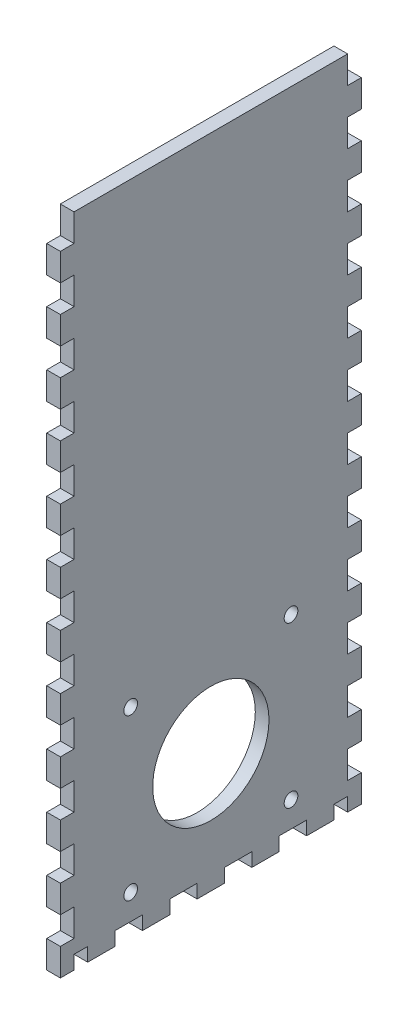
from build123d import *

# Parameters (mm, degrees)
SKETCH1_W              = 273.05
SKETCH1_H              = 139.7
BOSS_EXTRUDE1_DEPTH    = 6.35
SKETCH2_W              = 273.05
SKETCH2_H              = 139.7
SKETCH2_W_2            = 260.35
SKETCH2_H_2            = 127
BOSS_EXTRUDE2_DEPTH    = 298.45
SKETCH3_W              = 6.35
SKETCH3_H              = 16.933333333
SKETCH3_H_2            = 16.933333334
DOOR_SLOT_DEPTH        = 12.7
DOOR_GUIDE_HOLES_REACH = 361.617
SKETCH4_W              = 6.35
SKETCH4_H              = 15.875
LEVER_HOLES_W          = 9.652
LEVER_HOLES_H          = 6.35
LEVER_HOLES_W_2        = 6.35
CUT_EXTRUDE1_DEPTH     = 363.019620497
CUT_EXTRUDE2_REACH     = 417.137
SKETCH7_R              = 26.9875
CUT_EXTRUDE3_REACH     = 417.137
SKETCH8_R              = 3.175
SKETCH16_W             = 326.476778096
SKETCH16_H             = 315.233565403
CUT_EXTRUDE10_DEPTH    = 363.019620497
LEFT_RIGHT_W           = 6.35
LEFT_RIGHT_H           = 6.35
LEFT_RIGHT_W_2         = 12.7
LEFT_RIGHT_H_2         = 12.7
CUT_EXTRUDE11_DEPTH    = 416.136561869


with BuildPart() as part:
    # Sketch1 → Boss-Extrude1 (new body)
    with BuildSketch(Plane(origin=(0, 0, 0), x_dir=(1, 0, 0), z_dir=(0, 1, 0))):
        Rectangle(SKETCH1_W, SKETCH1_H)
    extrude(amount=BOSS_EXTRUDE1_DEPTH)

    # Sketch2 → Boss-Extrude2 (add)
    with BuildSketch(Plane(origin=(0, 6.35, 0), x_dir=(1, 0, 0), z_dir=(0, 1, 0))):
        Rectangle(SKETCH2_W, SKETCH2_H)
        Rectangle(SKETCH2_W_2, SKETCH2_H_2, mode=Mode.SUBTRACT)
    extrude(amount=BOSS_EXTRUDE2_DEPTH)

    # Sketch3 → Door Slot (cut)
    with BuildSketch(Plane.XY.offset(69.85)):
        with BuildLine():
            Line((-28.575, 283.21), (-28.575, 6.35))
            Line((-28.575, 6.35), (-21.971, 6.35))
            Line((-21.971, 6.35), (-21.971, 292.354))
            Line((-21.971, 292.354), (-41.529, 292.354))
            Line((-41.529, 292.354), (-41.529, 285.75))
            Line((-41.529, 285.75), (-31.115, 285.75))
            ThreePointArc((-31.115, 285.75), (-29.318948776, 285.006051224), (-28.575, 283.21))
        make_face()
        with Locations((-12.446, 80.433333334)):
            Rectangle(SKETCH3_W, SKETCH3_H)
        with Locations((-12.446, 50.8)):
            Rectangle(SKETCH3_W, SKETCH3_H_2)
        with Locations((-12.446, 21.166666667)):
            Rectangle(SKETCH3_W, SKETCH3_H)
    extrude(amount=-DOOR_SLOT_DEPTH, mode=Mode.SUBTRACT)

    # Sketch4 → Door Guide Holes (cut, up to next)
    with BuildSketch(Plane.XY.offset(-63.5), mode=Mode.PRIVATE) as door_guide_holes_sk1:
        with Locations((-44.704, 284.1625)):
            Rectangle(SKETCH4_W, SKETCH4_H)
    door_guide_holes_tool1 = extrude(door_guide_holes_sk1.sketch, amount=-DOOR_GUIDE_HOLES_REACH, mode=Mode.PRIVATE) & part.part
    # Sketch4 → Door Guide Holes (cut, up to next)
    with BuildSketch(Plane.XY.offset(-63.5), mode=Mode.PRIVATE) as door_guide_holes_sk2:
        with Locations((-44.704, 255.5875)):
            Rectangle(SKETCH4_W, SKETCH4_H)
    door_guide_holes_tool2 = extrude(door_guide_holes_sk2.sketch, amount=-DOOR_GUIDE_HOLES_REACH, mode=Mode.PRIVATE) & part.part
    # Sketch4 → Door Guide Holes (cut, up to next)
    with BuildSketch(Plane.XY.offset(-63.5), mode=Mode.PRIVATE) as door_guide_holes_sk3:
        with Locations((-44.704, 227.0125)):
            Rectangle(SKETCH4_W, SKETCH4_H)
    door_guide_holes_tool3 = extrude(door_guide_holes_sk3.sketch, amount=-DOOR_GUIDE_HOLES_REACH, mode=Mode.PRIVATE) & part.part
    # Sketch4 → Door Guide Holes (cut, up to next)
    with BuildSketch(Plane.XY.offset(-63.5), mode=Mode.PRIVATE) as door_guide_holes_sk4:
        with Locations((-44.704, 198.4375)):
            Rectangle(SKETCH4_W, SKETCH4_H)
    door_guide_holes_tool4 = extrude(door_guide_holes_sk4.sketch, amount=-DOOR_GUIDE_HOLES_REACH, mode=Mode.PRIVATE) & part.part
    # Sketch4 → Door Guide Holes (cut, up to next)
    with BuildSketch(Plane.XY.offset(-63.5), mode=Mode.PRIVATE) as door_guide_holes_sk5:
        with Locations((-44.704, 169.8625)):
            Rectangle(SKETCH4_W, SKETCH4_H)
    door_guide_holes_tool5 = extrude(door_guide_holes_sk5.sketch, amount=-DOOR_GUIDE_HOLES_REACH, mode=Mode.PRIVATE) & part.part
    # Sketch4 → Door Guide Holes (cut, up to next)
    with BuildSketch(Plane.XY.offset(-63.5), mode=Mode.PRIVATE) as door_guide_holes_sk6:
        with Locations((-44.704, 141.2875)):
            Rectangle(SKETCH4_W, SKETCH4_H)
    door_guide_holes_tool6 = extrude(door_guide_holes_sk6.sketch, amount=-DOOR_GUIDE_HOLES_REACH, mode=Mode.PRIVATE) & part.part
    # Sketch4 → Door Guide Holes (cut, up to next)
    with BuildSketch(Plane.XY.offset(-63.5), mode=Mode.PRIVATE) as door_guide_holes_sk7:
        with Locations((-44.704, 112.7125)):
            Rectangle(SKETCH4_W, SKETCH4_H)
    door_guide_holes_tool7 = extrude(door_guide_holes_sk7.sketch, amount=-DOOR_GUIDE_HOLES_REACH, mode=Mode.PRIVATE) & part.part
    # Sketch4 → Door Guide Holes (cut, up to next)
    with BuildSketch(Plane.XY.offset(-63.5), mode=Mode.PRIVATE) as door_guide_holes_sk8:
        with Locations((-44.704, 84.1375)):
            Rectangle(SKETCH4_W, SKETCH4_H)
    door_guide_holes_tool8 = extrude(door_guide_holes_sk8.sketch, amount=-DOOR_GUIDE_HOLES_REACH, mode=Mode.PRIVATE) & part.part
    # Sketch4 → Door Guide Holes (cut, up to next)
    with BuildSketch(Plane.XY.offset(-63.5), mode=Mode.PRIVATE) as door_guide_holes_sk9:
        with Locations((-44.704, 55.5625)):
            Rectangle(SKETCH4_W, SKETCH4_H)
    door_guide_holes_tool9 = extrude(door_guide_holes_sk9.sketch, amount=-DOOR_GUIDE_HOLES_REACH, mode=Mode.PRIVATE) & part.part
    # Sketch4 → Door Guide Holes (cut, up to next)
    with BuildSketch(Plane.XY.offset(-63.5), mode=Mode.PRIVATE) as door_guide_holes_sk10:
        with Locations((-44.704, 26.9875)):
            Rectangle(SKETCH4_W, SKETCH4_H)
    door_guide_holes_tool10 = extrude(door_guide_holes_sk10.sketch, amount=-DOOR_GUIDE_HOLES_REACH, mode=Mode.PRIVATE) & part.part
    door_guide_holes_1 = door_guide_holes_tool1.solids().sort_by_distance((-44.704, 284.1625, -63.5))[0]
    add(door_guide_holes_1, mode=Mode.SUBTRACT)
    door_guide_holes_2 = door_guide_holes_tool2.solids().sort_by_distance((-44.704, 255.5875, -63.5))[0]
    add(door_guide_holes_2, mode=Mode.SUBTRACT)
    door_guide_holes_3 = door_guide_holes_tool3.solids().sort_by_distance((-44.704, 227.0125, -63.5))[0]
    add(door_guide_holes_3, mode=Mode.SUBTRACT)
    door_guide_holes_4 = door_guide_holes_tool4.solids().sort_by_distance((-44.704, 198.4375, -63.5))[0]
    add(door_guide_holes_4, mode=Mode.SUBTRACT)
    door_guide_holes_5 = door_guide_holes_tool5.solids().sort_by_distance((-44.704, 169.8625, -63.5))[0]
    add(door_guide_holes_5, mode=Mode.SUBTRACT)
    door_guide_holes_6 = door_guide_holes_tool6.solids().sort_by_distance((-44.704, 141.2875, -63.5))[0]
    add(door_guide_holes_6, mode=Mode.SUBTRACT)
    door_guide_holes_7 = door_guide_holes_tool7.solids().sort_by_distance((-44.704, 112.7125, -63.5))[0]
    add(door_guide_holes_7, mode=Mode.SUBTRACT)
    door_guide_holes_8 = door_guide_holes_tool8.solids().sort_by_distance((-44.704, 84.1375, -63.5))[0]
    add(door_guide_holes_8, mode=Mode.SUBTRACT)
    door_guide_holes_9 = door_guide_holes_tool9.solids().sort_by_distance((-44.704, 55.5625, -63.5))[0]
    add(door_guide_holes_9, mode=Mode.SUBTRACT)
    door_guide_holes_10 = door_guide_holes_tool10.solids().sort_by_distance((-44.704, 26.9875, -63.5))[0]
    add(door_guide_holes_10, mode=Mode.SUBTRACT)
    door_guide_holes = door_guide_holes_1 + door_guide_holes_2 + door_guide_holes_3 + door_guide_holes_4 + door_guide_holes_5 + door_guide_holes_6 + door_guide_holes_7 + door_guide_holes_8 + door_guide_holes_9 + door_guide_holes_10  # Door Guide Holes as one shape, for the pattern or mirror that repeats it

    # Mirror1: Door Guide Holes across plane
    add(door_guide_holes.mirror(Plane.ZY.offset(31.75)), mode=Mode.SUBTRACT)

    # Lever Holes → Cut-Extrude1 (cut, through all)
    with BuildSketch(Plane.XY.offset(69.85)):
        with Locations((54.102, 28.575)):
            Rectangle(LEVER_HOLES_W, LEVER_HOLES_H)
        with Locations((39.3065, 15.875)):
            Rectangle(LEVER_HOLES_W_2, LEVER_HOLES_H)
        with Locations((68.8975, 15.875)):
            Rectangle(LEVER_HOLES_W_2, LEVER_HOLES_H)
    extrude(amount=-CUT_EXTRUDE1_DEPTH, mode=Mode.SUBTRACT)

    # Sketch7 → Cut-Extrude2 (cut, up to next)
    with BuildSketch(Plane(origin=(136.525, 0, 0), x_dir=(0, 0, -1), z_dir=(1, 0, 0)), mode=Mode.PRIVATE) as cut_extrude2_sk1:
        with Locations((0, 55.372)):
            Circle(SKETCH7_R)
    cut_extrude2_tool1 = extrude(cut_extrude2_sk1.sketch, amount=-CUT_EXTRUDE2_REACH, mode=Mode.PRIVATE) & part.part
    # Sketch7 → Cut-Extrude2 (cut, up to next)
    with BuildSketch(Plane(origin=(136.525, 0, 0), x_dir=(0, 0, -1), z_dir=(1, 0, 0)), mode=Mode.PRIVATE) as cut_extrude2_sk2:
        with BuildLine():
            Line((-37.211, 89.408), (-37.211, 92.583))
            Line((-37.211, 92.583), (-34.036, 92.583))
            ThreePointArc((-34.036, 92.583), (-39.45606403, 94.82806403), (-37.211, 89.408))
        make_face()
    cut_extrude2_tool2 = extrude(cut_extrude2_sk2.sketch, amount=-CUT_EXTRUDE2_REACH, mode=Mode.PRIVATE) & part.part
    # Sketch7 → Cut-Extrude2 (cut, up to next)
    with BuildSketch(Plane(origin=(136.525, 0, 0), x_dir=(0, 0, -1), z_dir=(1, 0, 0)), mode=Mode.PRIVATE) as cut_extrude2_sk3:
        with BuildLine():
            Line((-34.036, 92.583), (-37.211, 92.583))
            Line((-37.211, 92.583), (-37.211, 89.408))
            ThreePointArc((-37.211, 89.408), (-34.96593597, 90.33793597), (-34.036, 92.583))
        make_face()
    cut_extrude2_tool3 = extrude(cut_extrude2_sk3.sketch, amount=-CUT_EXTRUDE2_REACH, mode=Mode.PRIVATE) & part.part
    # Sketch7 → Cut-Extrude2 (cut, up to next)
    with BuildSketch(Plane(origin=(136.525, 0, 0), x_dir=(0, 0, -1), z_dir=(1, 0, 0)), mode=Mode.PRIVATE) as cut_extrude2_sk4:
        with BuildLine():
            Line((-37.211, 89.408), (-37.211, 92.583))
            Line((-37.211, 92.583), (-34.036, 92.583))
            ThreePointArc((-34.036, 92.583), (-39.45606403, 94.82806403), (-37.211, 89.408))
        make_face()
    cut_extrude2_tool4 = extrude(cut_extrude2_sk4.sketch, amount=-CUT_EXTRUDE2_REACH, mode=Mode.PRIVATE) & part.part
    # Sketch7 → Cut-Extrude2 (cut, up to next)
    with BuildSketch(Plane(origin=(136.525, 0, 0), x_dir=(0, 0, -1), z_dir=(1, 0, 0)), mode=Mode.PRIVATE) as cut_extrude2_sk5:
        with BuildLine():
            Line((-34.036, 92.583), (-37.211, 92.583))
            Line((-37.211, 92.583), (-37.211, 89.408))
            ThreePointArc((-37.211, 89.408), (-34.96593597, 90.33793597), (-34.036, 92.583))
        make_face()
    cut_extrude2_tool5 = extrude(cut_extrude2_sk5.sketch, amount=-CUT_EXTRUDE2_REACH, mode=Mode.PRIVATE) & part.part
    # Sketch7 → Cut-Extrude2 (cut, up to next)
    with BuildSketch(Plane(origin=(136.525, 0, 0), x_dir=(0, 0, -1), z_dir=(1, 0, 0)), mode=Mode.PRIVATE) as cut_extrude2_sk6:
        with BuildLine():
            ThreePointArc((40.386, 92.583), (37.211, 95.758), (34.036, 92.583))
            Line((34.036, 92.583), (37.211, 92.583))
            Line((37.211, 92.583), (37.211, 89.408))
            ThreePointArc((37.211, 89.408), (39.45606403, 90.33793597), (40.386, 92.583))
        make_face()
    cut_extrude2_tool6 = extrude(cut_extrude2_sk6.sketch, amount=-CUT_EXTRUDE2_REACH, mode=Mode.PRIVATE) & part.part
    # Sketch7 → Cut-Extrude2 (cut, up to next)
    with BuildSketch(Plane(origin=(136.525, 0, 0), x_dir=(0, 0, -1), z_dir=(1, 0, 0)), mode=Mode.PRIVATE) as cut_extrude2_sk7:
        with BuildLine():
            Line((37.211, 92.583), (34.036, 92.583))
            ThreePointArc((34.036, 92.583), (34.96593597, 90.33793597), (37.211, 89.408))
            Line((37.211, 89.408), (37.211, 92.583))
        make_face()
    cut_extrude2_tool7 = extrude(cut_extrude2_sk7.sketch, amount=-CUT_EXTRUDE2_REACH, mode=Mode.PRIVATE) & part.part
    # Sketch7 → Cut-Extrude2 (cut, up to next)
    with BuildSketch(Plane(origin=(136.525, 0, 0), x_dir=(0, 0, -1), z_dir=(1, 0, 0)), mode=Mode.PRIVATE) as cut_extrude2_sk8:
        with BuildLine():
            ThreePointArc((40.386, 92.583), (37.211, 95.758), (34.036, 92.583))
            Line((34.036, 92.583), (37.211, 92.583))
            Line((37.211, 92.583), (37.211, 89.408))
            ThreePointArc((37.211, 89.408), (39.45606403, 90.33793597), (40.386, 92.583))
        make_face()
    cut_extrude2_tool8 = extrude(cut_extrude2_sk8.sketch, amount=-CUT_EXTRUDE2_REACH, mode=Mode.PRIVATE) & part.part
    # Sketch7 → Cut-Extrude2 (cut, up to next)
    with BuildSketch(Plane(origin=(136.525, 0, 0), x_dir=(0, 0, -1), z_dir=(1, 0, 0)), mode=Mode.PRIVATE) as cut_extrude2_sk9:
        with BuildLine():
            Line((37.211, 92.583), (34.036, 92.583))
            ThreePointArc((34.036, 92.583), (34.96593597, 90.33793597), (37.211, 89.408))
            Line((37.211, 89.408), (37.211, 92.583))
        make_face()
    cut_extrude2_tool9 = extrude(cut_extrude2_sk9.sketch, amount=-CUT_EXTRUDE2_REACH, mode=Mode.PRIVATE) & part.part
    # Sketch7 → Cut-Extrude2 (cut, up to next)
    with BuildSketch(Plane(origin=(136.525, 0, 0), x_dir=(0, 0, -1), z_dir=(1, 0, 0)), mode=Mode.PRIVATE) as cut_extrude2_sk10:
        with BuildLine():
            ThreePointArc((-34.036, 18.161), (-34.96593597, 20.40606403), (-37.211, 21.336))
            Line((-37.211, 21.336), (-37.211, 18.161))
            Line((-37.211, 18.161), (-34.036, 18.161))
        make_face()
    cut_extrude2_tool10 = extrude(cut_extrude2_sk10.sketch, amount=-CUT_EXTRUDE2_REACH, mode=Mode.PRIVATE) & part.part
    # Sketch7 → Cut-Extrude2 (cut, up to next)
    with BuildSketch(Plane(origin=(136.525, 0, 0), x_dir=(0, 0, -1), z_dir=(1, 0, 0)), mode=Mode.PRIVATE) as cut_extrude2_sk11:
        with BuildLine():
            Line((-37.211, 18.161), (-37.211, 21.336))
            ThreePointArc((-37.211, 21.336), (-39.45606403, 15.91593597), (-34.036, 18.161))
            Line((-34.036, 18.161), (-37.211, 18.161))
        make_face()
    cut_extrude2_tool11 = extrude(cut_extrude2_sk11.sketch, amount=-CUT_EXTRUDE2_REACH, mode=Mode.PRIVATE) & part.part
    # Sketch7 → Cut-Extrude2 (cut, up to next)
    with BuildSketch(Plane(origin=(136.525, 0, 0), x_dir=(0, 0, -1), z_dir=(1, 0, 0)), mode=Mode.PRIVATE) as cut_extrude2_sk12:
        with BuildLine():
            ThreePointArc((-34.036, 18.161), (-34.96593597, 20.40606403), (-37.211, 21.336))
            Line((-37.211, 21.336), (-37.211, 18.161))
            Line((-37.211, 18.161), (-34.036, 18.161))
        make_face()
    cut_extrude2_tool12 = extrude(cut_extrude2_sk12.sketch, amount=-CUT_EXTRUDE2_REACH, mode=Mode.PRIVATE) & part.part
    # Sketch7 → Cut-Extrude2 (cut, up to next)
    with BuildSketch(Plane(origin=(136.525, 0, 0), x_dir=(0, 0, -1), z_dir=(1, 0, 0)), mode=Mode.PRIVATE) as cut_extrude2_sk13:
        with BuildLine():
            Line((-37.211, 18.161), (-37.211, 21.336))
            ThreePointArc((-37.211, 21.336), (-39.45606403, 15.91593597), (-34.036, 18.161))
            Line((-34.036, 18.161), (-37.211, 18.161))
        make_face()
    cut_extrude2_tool13 = extrude(cut_extrude2_sk13.sketch, amount=-CUT_EXTRUDE2_REACH, mode=Mode.PRIVATE) & part.part
    # Sketch7 → Cut-Extrude2 (cut, up to next)
    with BuildSketch(Plane(origin=(136.525, 0, 0), x_dir=(0, 0, -1), z_dir=(1, 0, 0)), mode=Mode.PRIVATE) as cut_extrude2_sk14:
        with BuildLine():
            ThreePointArc((40.386, 18.161), (39.45606403, 20.40606403), (37.211, 21.336))
            Line((37.211, 21.336), (37.211, 18.161))
            Line((37.211, 18.161), (34.036, 18.161))
            ThreePointArc((34.036, 18.161), (37.211, 14.986), (40.386, 18.161))
        make_face()
    cut_extrude2_tool14 = extrude(cut_extrude2_sk14.sketch, amount=-CUT_EXTRUDE2_REACH, mode=Mode.PRIVATE) & part.part
    # Sketch7 → Cut-Extrude2 (cut, up to next)
    with BuildSketch(Plane(origin=(136.525, 0, 0), x_dir=(0, 0, -1), z_dir=(1, 0, 0)), mode=Mode.PRIVATE) as cut_extrude2_sk15:
        with BuildLine():
            Line((37.211, 18.161), (37.211, 21.336))
            ThreePointArc((37.211, 21.336), (34.96593597, 20.40606403), (34.036, 18.161))
            Line((34.036, 18.161), (37.211, 18.161))
        make_face()
    cut_extrude2_tool15 = extrude(cut_extrude2_sk15.sketch, amount=-CUT_EXTRUDE2_REACH, mode=Mode.PRIVATE) & part.part
    # Sketch7 → Cut-Extrude2 (cut, up to next)
    with BuildSketch(Plane(origin=(136.525, 0, 0), x_dir=(0, 0, -1), z_dir=(1, 0, 0)), mode=Mode.PRIVATE) as cut_extrude2_sk16:
        with BuildLine():
            ThreePointArc((40.386, 18.161), (39.45606403, 20.40606403), (37.211, 21.336))
            Line((37.211, 21.336), (37.211, 18.161))
            Line((37.211, 18.161), (34.036, 18.161))
            ThreePointArc((34.036, 18.161), (37.211, 14.986), (40.386, 18.161))
        make_face()
    cut_extrude2_tool16 = extrude(cut_extrude2_sk16.sketch, amount=-CUT_EXTRUDE2_REACH, mode=Mode.PRIVATE) & part.part
    # Sketch7 → Cut-Extrude2 (cut, up to next)
    with BuildSketch(Plane(origin=(136.525, 0, 0), x_dir=(0, 0, -1), z_dir=(1, 0, 0)), mode=Mode.PRIVATE) as cut_extrude2_sk17:
        with BuildLine():
            Line((37.211, 18.161), (37.211, 21.336))
            ThreePointArc((37.211, 21.336), (34.96593597, 20.40606403), (34.036, 18.161))
            Line((34.036, 18.161), (37.211, 18.161))
        make_face()
    cut_extrude2_tool17 = extrude(cut_extrude2_sk17.sketch, amount=-CUT_EXTRUDE2_REACH, mode=Mode.PRIVATE) & part.part
    add(cut_extrude2_tool1.solids().sort_by_distance((136.525, 55.372, 0))[0], mode=Mode.SUBTRACT)
    add(cut_extrude2_tool2.solids().sort_by_distance((136.525, 93.032171, 37.660171))[0], mode=Mode.SUBTRACT)
    add(cut_extrude2_tool3.solids().sort_by_distance((136.525, 91.235488, 35.863488))[0], mode=Mode.SUBTRACT)
    add(cut_extrude2_tool4.solids().sort_by_distance((136.525, 93.032171, 37.660171))[0], mode=Mode.SUBTRACT)
    add(cut_extrude2_tool5.solids().sort_by_distance((136.525, 91.235488, 35.863488))[0], mode=Mode.SUBTRACT)
    add(cut_extrude2_tool6.solids().sort_by_distance((136.525, 93.032171, -37.660171))[0], mode=Mode.SUBTRACT)
    add(cut_extrude2_tool7.solids().sort_by_distance((136.525, 91.235488, -35.863488))[0], mode=Mode.SUBTRACT)
    add(cut_extrude2_tool8.solids().sort_by_distance((136.525, 93.032171, -37.660171))[0], mode=Mode.SUBTRACT)
    add(cut_extrude2_tool9.solids().sort_by_distance((136.525, 91.235488, -35.863488))[0], mode=Mode.SUBTRACT)
    add(cut_extrude2_tool10.solids().sort_by_distance((136.525, 19.508512, 35.863488))[0], mode=Mode.SUBTRACT)
    add(cut_extrude2_tool11.solids().sort_by_distance((136.525, 17.711829, 37.660171))[0], mode=Mode.SUBTRACT)
    add(cut_extrude2_tool12.solids().sort_by_distance((136.525, 19.508512, 35.863488))[0], mode=Mode.SUBTRACT)
    add(cut_extrude2_tool13.solids().sort_by_distance((136.525, 17.711829, 37.660171))[0], mode=Mode.SUBTRACT)
    add(cut_extrude2_tool14.solids().sort_by_distance((136.525, 17.711829, -37.660171))[0], mode=Mode.SUBTRACT)
    add(cut_extrude2_tool15.solids().sort_by_distance((136.525, 19.508512, -35.863488))[0], mode=Mode.SUBTRACT)
    add(cut_extrude2_tool16.solids().sort_by_distance((136.525, 17.711829, -37.660171))[0], mode=Mode.SUBTRACT)
    add(cut_extrude2_tool17.solids().sort_by_distance((136.525, 19.508512, -35.863488))[0], mode=Mode.SUBTRACT)

    # Sketch8 → Cut-Extrude3 (cut, up to next)
    with BuildSketch(Plane.ZY.offset(136.525), mode=Mode.PRIVATE) as cut_extrude3_sk1:
        with Locations((0, 19.05)):
            Circle(SKETCH8_R)
    cut_extrude3_tool1 = extrude(cut_extrude3_sk1.sketch, amount=-CUT_EXTRUDE3_REACH, mode=Mode.PRIVATE) & part.part
    add(cut_extrude3_tool1.solids().sort_by_distance((-136.525, 19.05, 0))[0], mode=Mode.SUBTRACT)

    # Sketch16 → Cut-Extrude10 (cut, through all)
    with BuildSketch(Plane.XY.offset(69.85)):
        with Locations((-33.063389048, 147.183217299)):
            Rectangle(SKETCH16_W, SKETCH16_H)
    extrude(amount=-CUT_EXTRUDE10_DEPTH, mode=Mode.SUBTRACT)

    # Left/Right → Cut-Extrude11 (cut, through all)
    with BuildSketch(Plane.ZY.offset(136.525)):
        with Locations((60.325, 3.175)):
            Rectangle(LEFT_RIGHT_W, LEFT_RIGHT_H)
        with Locations((38.1, 3.175)):
            Rectangle(LEFT_RIGHT_W_2, LEFT_RIGHT_H)
        with Locations((66.675, 19.05)):
            Rectangle(LEFT_RIGHT_W, LEFT_RIGHT_H_2)
        with Locations((12.7, 3.175)):
            Rectangle(LEFT_RIGHT_W_2, LEFT_RIGHT_H)
        with Locations((66.675, 44.45)):
            Rectangle(LEFT_RIGHT_W, LEFT_RIGHT_H_2)
        with Locations((-12.7, 3.175)):
            Rectangle(LEFT_RIGHT_W_2, LEFT_RIGHT_H)
        with Locations((66.675, 69.85)):
            Rectangle(LEFT_RIGHT_W, LEFT_RIGHT_H_2)
        with Locations((-38.1, 3.175)):
            Rectangle(LEFT_RIGHT_W_2, LEFT_RIGHT_H)
        with Locations((66.675, 95.25)):
            Rectangle(LEFT_RIGHT_W, LEFT_RIGHT_H_2)
        with Locations((-60.325, 3.175)):
            Rectangle(LEFT_RIGHT_W, LEFT_RIGHT_H)
        with Locations((66.675, 120.65)):
            Rectangle(LEFT_RIGHT_W, LEFT_RIGHT_H_2)
        with Locations((-66.675, 19.05)):
            Rectangle(LEFT_RIGHT_W, LEFT_RIGHT_H_2)
        with Locations((66.675, 146.05)):
            Rectangle(LEFT_RIGHT_W, LEFT_RIGHT_H_2)
        with Locations((-66.675, 44.45)):
            Rectangle(LEFT_RIGHT_W, LEFT_RIGHT_H_2)
        with Locations((66.675, 171.45)):
            Rectangle(LEFT_RIGHT_W, LEFT_RIGHT_H_2)
        with Locations((-66.675, 69.85)):
            Rectangle(LEFT_RIGHT_W, LEFT_RIGHT_H_2)
        with Locations((66.675, 196.85)):
            Rectangle(LEFT_RIGHT_W, LEFT_RIGHT_H_2)
        with Locations((-66.675, 95.25)):
            Rectangle(LEFT_RIGHT_W, LEFT_RIGHT_H_2)
        with Locations((66.675, 222.25)):
            Rectangle(LEFT_RIGHT_W, LEFT_RIGHT_H_2)
        with Locations((-66.675, 120.65)):
            Rectangle(LEFT_RIGHT_W, LEFT_RIGHT_H_2)
        with Locations((66.675, 247.65)):
            Rectangle(LEFT_RIGHT_W, LEFT_RIGHT_H_2)
        with Locations((-66.675, 146.05)):
            Rectangle(LEFT_RIGHT_W, LEFT_RIGHT_H_2)
        with Locations((66.675, 273.05)):
            Rectangle(LEFT_RIGHT_W, LEFT_RIGHT_H_2)
        with Locations((-66.675, 171.45)):
            Rectangle(LEFT_RIGHT_W, LEFT_RIGHT_H_2)
        with Locations((66.675, 298.45)):
            Rectangle(LEFT_RIGHT_W, LEFT_RIGHT_H_2)
        with Locations((-66.675, 196.85)):
            Rectangle(LEFT_RIGHT_W, LEFT_RIGHT_H_2)
        with Locations((-66.675, 222.25)):
            Rectangle(LEFT_RIGHT_W, LEFT_RIGHT_H_2)
        with Locations((-66.675, 247.65)):
            Rectangle(LEFT_RIGHT_W, LEFT_RIGHT_H_2)
        with Locations((-66.675, 273.05)):
            Rectangle(LEFT_RIGHT_W, LEFT_RIGHT_H_2)
        with Locations((-66.675, 298.45)):
            Rectangle(LEFT_RIGHT_W, LEFT_RIGHT_H_2)
    extrude(amount=-CUT_EXTRUDE11_DEPTH, mode=Mode.SUBTRACT)


solid = part.part
